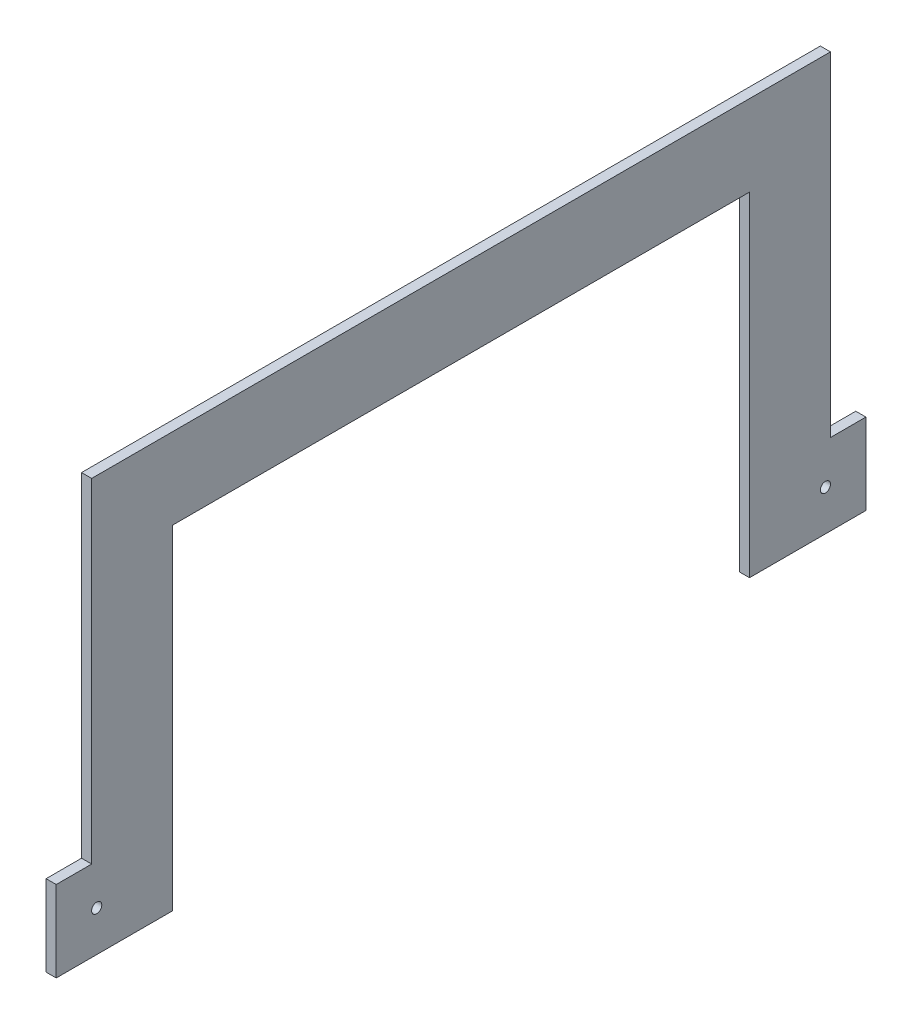
from build123d import *

# Parameters (mm, degrees)
BOSS_EXTRUDE1_DEPTH = 3.175
SKETCH2_R           = 1.5875
CUT_EXTRUDE1_DEPTH  = 4.175


with BuildPart() as part:
    # Sketch1 → Boss-Extrude1 (new body)
    with BuildSketch(Plane(origin=(0, 0, 0), x_dir=(0, 0, -1), z_dir=(1, 0, 0))):
        Polygon((-90.4875, 0), (90.4875, 0), (90.4875, -104.775), (127, -104.775), (127, -79.375), (115.8875, -79.375), (115.8875, 25.4), (-115.8875, 25.4), (-115.8875, -79.375), (-127, -79.375), (-127, -104.775), (-90.4875, -104.775), align=None)
    extrude(amount=BOSS_EXTRUDE1_DEPTH)

    # Sketch2 → Cut-Extrude1 (cut, through all)
    with BuildSketch(Plane(origin=(3.175, 0, 0), x_dir=(0, 0, -1), z_dir=(1, 0, 0))):
        with Locations((-114.3, -92.075)):
            Circle(SKETCH2_R)
        with Locations((114.3, -92.075)):
            Circle(SKETCH2_R)
    extrude(amount=-CUT_EXTRUDE1_DEPTH, mode=Mode.SUBTRACT)


solid = part.part
